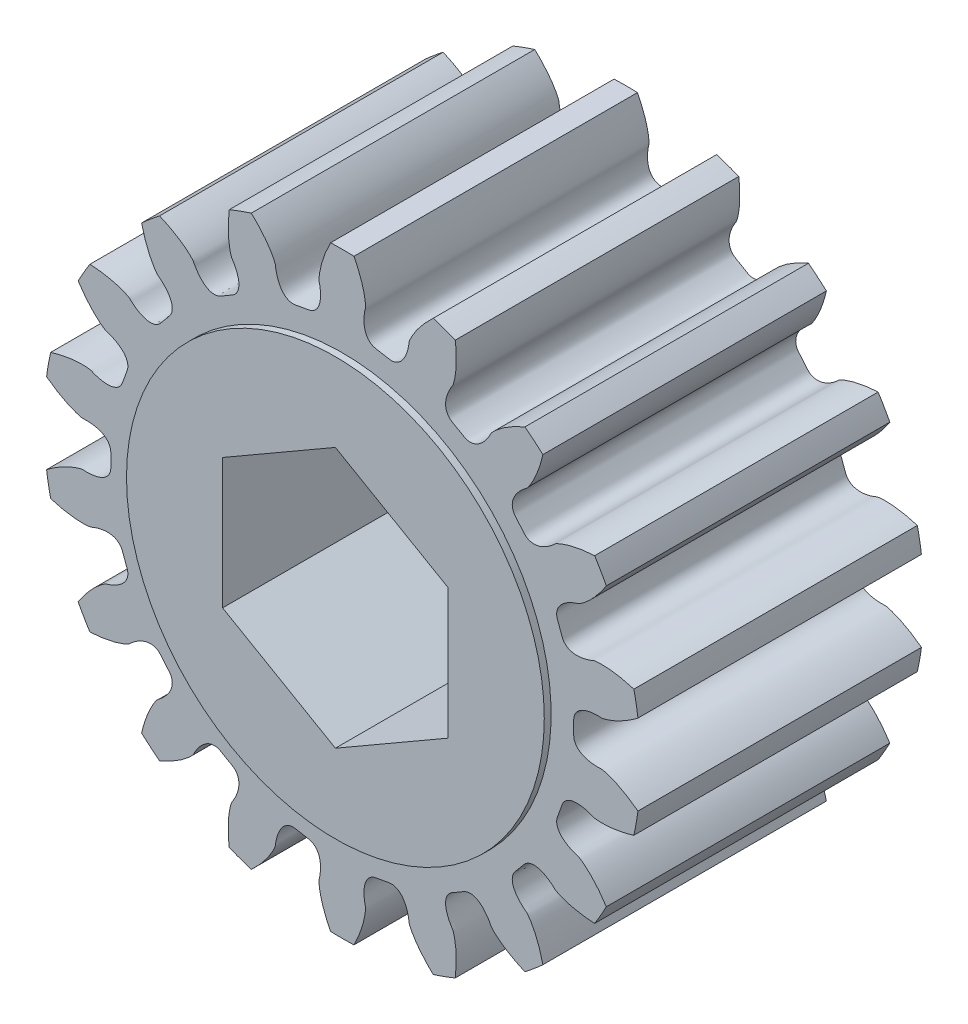
from build123d import *

# Parameters (mm, degrees)
BOSS_EXTRUDE1_DEPTH = 12.065
SKETCH2_R           = 8.89
BOSS_EXTRUDE2_DEPTH = 0.2921
SKETCH3_R           = 8.89
BOSS_EXTRUDE3_DEPTH = 0.2921
CUT_EXTRUDE1_DEPTH  = 13.6492


with BuildPart() as part:
    # Sketch1 → Boss-Extrude1 (new body)
    with BuildSketch(Plane.XY.offset(6.0325)):
        with BuildLine():
            ThreePointArc((12.410970883, -2.694030306), (12.507058369, -2.205331838), (12.583910389, -1.713241638))
            add(Edge.make_bspline(
                [(12.583910389, -1.713241638), (12.454495513, -1.615266365), (12.281691884, -1.494600081), (12.063530587, -1.360821083), (11.945634884, -1.293014345), (11.833605036, -1.232708673), (11.727763905, -1.179517154), (11.628417021, -1.133040061), (11.535852234, -1.09286743), (11.450339429, -1.058575143), (11.372129731, -1.029740178), (11.301456539, -1.005894736), (11.238530851, -0.986673766), (11.183554417, -0.971362731), (11.126066888, -0.957744243), (11.037383924, -0.935500863), (10.935383555, -0.952855993), (10.832757273, -0.948980949), (10.755684694, -0.945835715), (10.681454151, -0.939599556), (10.609986165, -0.931080188), (10.541241018, -0.920104184), (10.475144099, -0.906715101), (10.411601978, -0.890856967), (10.350496087, -0.872438809), (10.291684118, -0.851296022), (10.23500406, -0.827170041), (10.180287123, -0.799673241), (10.127386898, -0.768246797), (10.076238411, -0.732113156), (10.026966573, -0.690238537), (9.98006979, -0.641341891), (9.936675165, -0.584030203), (9.898843597, -0.517153755), (9.869552788, -0.440522263), (9.854050846, -0.362318712), (9.847049326, -0.214546824), (9.861767648, -5e-09), (9.847049326, 0.214546814), (9.854050846, 0.362318702), (9.869552789, 0.440522252), (9.898843597, 0.517153744), (9.936675165, 0.584030193), (9.980069791, 0.641341881), (10.026966574, 0.690238527), (10.076238412, 0.732113146), (10.127386899, 0.768246787), (10.180287124, 0.79967323), (10.235004061, 0.82717003), (10.291684119, 0.851296011), (10.350496088, 0.872438798), (10.411601979, 0.890856956), (10.4751441, 0.90671509), (10.541241019, 0.920104174), (10.609986166, 0.931080178), (10.681454152, 0.939599545), (10.755684695, 0.945835704), (10.832757274, 0.948980938), (10.935383556, 0.952855982), (11.037383925, 0.935500852), (11.126066889, 0.957744232), (11.183554418, 0.97136272), (11.238530852, 0.986673755), (11.30145654, 1.005894724), (11.372129732, 1.029740166), (11.45033943, 1.058575132), (11.535852235, 1.092867418), (11.628417022, 1.133040049), (11.727763907, 1.179517142), (11.833605037, 1.23270866), (11.945634885, 1.293014333), (12.063530588, 1.360821071), (12.281691885, 1.494600068), (12.454495515, 1.615266353), (12.58391039, 1.713241625)],
                knots=[0, 0, 0, 0, 0.068568258, 0.088954796, 0.108105787, 0.12602123, 0.142701125, 0.158145472, 0.172354272, 0.185327523, 0.197065227, 0.207567384, 0.216833992, 0.224865053, 0.231660567, 0.241835881, 0.263155637, 0.274398239, 0.285253325, 0.295735543, 0.30586243, 0.315655123, 0.325139277, 0.334346238, 0.343314557, 0.352091904, 0.360737466, 0.369324816, 0.377945084, 0.386709838, 0.395752205, 0.405223204, 0.415278018, 0.42604547, 0.437577809, 0.44979349, 0.459544035, 0.500000005, 0.540455975, 0.550206519, 0.5624222, 0.573954539, 0.584721991, 0.594776805, 0.604247805, 0.613290172, 0.622054925, 0.630675194, 0.639262544, 0.647908106, 0.656685453, 0.665653771, 0.674860733, 0.684344886, 0.69413758, 0.704264467, 0.714746685, 0.725601771, 0.736844372, 0.758164128, 0.768339443, 0.775134956, 0.783166017, 0.792432626, 0.802934782, 0.814672486, 0.827645738, 0.841854537, 0.857298885, 0.87397878, 0.891894222, 0.911045213, 0.931431751, 1.000000005, 1.000000005, 1.000000005, 1.000000005], degree=3))
            ThreePointArc((12.58391039, 1.713241625), (12.507058371, 2.205331832), (12.410970883, 2.694030306))
            add(Edge.make_bspline(
                [(12.410970883, 2.694030306), (12.255851163, 2.741834452), (12.052198568, 2.796121347), (11.801438895, 2.847216926), (11.667461903, 2.870611712), (11.541562526, 2.888964043), (11.423911826, 2.902747921), (11.31466019, 2.912443467), (11.213937893, 2.91853437), (11.121853489, 2.921511477), (11.038498274, 2.921858189), (10.963931576, 2.92009392), (10.898226812, 2.91663387), (10.84132918, 2.912218489), (10.782650776, 2.905353789), (10.691708366, 2.895924368), (10.601795176, 2.8447297), (10.504032672, 2.813270795), (10.430532405, 2.789865973), (10.35864562, 2.770337704), (10.288573885, 2.7538998), (10.220220564, 2.740701645), (10.153530441, 2.730676791), (10.088396577, 2.723845877), (10.024676441, 2.720253838), (9.962180009, 2.720006681), (9.900666605, 2.723291966), (9.839845043, 2.730416211), (9.779386616, 2.741854465), (9.718964327, 2.758315169), (9.658341981, 2.780812478), (9.597549782, 2.810720651), (9.537170421, 2.849734185), (9.478747284, 2.899638332), (9.425013413, 2.961630333), (9.383699162, 3.029815656), (9.326578923, 3.166281147), (9.267030288, 3.372923173), (9.179820255, 3.569497273), (9.13585857, 3.710752086), (9.123678441, 3.789541362), (9.124993284, 3.871569456), (9.137670236, 3.94735192), (9.158846094, 4.016049126), (9.186191017, 4.078036588), (9.218169437, 4.13423782), (9.253874859, 4.185686149), (9.292836333, 4.233310288), (9.334848976, 4.277863123), (9.379859237, 4.319919851), (9.427893151, 4.359902449), (9.479014525, 4.398109302), (9.533300786, 4.434743759), (9.590832237, 4.46993186), (9.651677529, 4.503758155), (9.715921673, 4.536207233), (9.783542674, 4.567455646), (9.854891475, 4.596771573), (9.950003292, 4.63551318), (10.05178809, 4.654090873), (10.127515133, 4.705324173), (10.176877942, 4.737783259), (10.223302209, 4.770973973), (10.275859055, 4.810557629), (10.33411451, 4.85713667), (10.397745447, 4.910981967), (10.466372546, 4.972453278), (10.539615145, 5.041862224), (10.617074577, 5.119515041), (10.698340136, 5.205698517), (10.782988003, 5.300683777), (10.870582454, 5.404723974), (11.029831903, 5.605050669), (11.150943898, 5.777542208), (11.239044585, 5.913871343)],
                knots=[0, 0, 0, 0, 0.068568258, 0.088954796, 0.108105787, 0.12602123, 0.142701125, 0.158145472, 0.172354272, 0.185327523, 0.197065227, 0.207567384, 0.216833992, 0.224865053, 0.231660567, 0.241835881, 0.263155637, 0.274398239, 0.285253325, 0.295735543, 0.30586243, 0.315655123, 0.325139277, 0.334346238, 0.343314557, 0.352091904, 0.360737466, 0.369324816, 0.377945084, 0.386709838, 0.395752205, 0.405223204, 0.415278018, 0.42604547, 0.437577809, 0.44979349, 0.459544035, 0.500000005, 0.540455975, 0.550206519, 0.5624222, 0.573954539, 0.584721991, 0.594776805, 0.604247805, 0.613290172, 0.622054925, 0.630675194, 0.639262544, 0.647908106, 0.656685453, 0.665653771, 0.674860733, 0.684344886, 0.69413758, 0.704264467, 0.714746685, 0.725601771, 0.736844372, 0.758164128, 0.768339443, 0.775134956, 0.783166017, 0.792432626, 0.802934782, 0.814672486, 0.827645738, 0.841854537, 0.857298885, 0.87397878, 0.891894222, 0.911045213, 0.931431751, 1.000000005, 1.000000005, 1.000000005, 1.000000005], degree=3))
            ThreePointArc((11.239044585, 5.913871343), (10.998522549, 6.349999934), (10.741085127, 6.776362423))
            add(Edge.make_bspline(
                [(10.741085127, 6.776362423), (10.57897029, 6.768229557), (10.369032237, 6.749589262), (10.115919506, 6.711838541), (9.982020827, 6.687999619), (9.857437245, 6.662185046), (9.742167386, 6.634898745), (9.636188358, 6.606643318), (9.539457148, 6.57791784), (9.451907882, 6.549220684), (9.373461019, 6.521037324), (9.303994658, 6.493876141), (9.243435784, 6.468152405), (9.191479648, 6.444543168), (9.138687851, 6.418023263), (9.05645499, 6.378058371), (8.989473837, 6.299198996), (8.908366713, 6.23620055), (8.847303975, 6.189068639), (8.786431555, 6.146131341), (8.726207757, 6.106718819), (8.66649068, 6.070938398), (8.607251166, 6.03870875), (8.548381665, 6.010012697), (8.489732872, 5.984843715), (8.431089969, 5.963236424), (8.372162644, 5.945284759), (8.312572436, 5.931177161), (8.251847984, 5.921247604), (8.189439713, 5.916049966), (8.124778809, 5.916456458), (8.057423631, 5.92376879), (7.987342176, 5.939778563), (7.915374162, 5.966691232), (7.843678327, 6.006566591), (7.781534876, 6.05650953), (7.681185462, 6.165208873), (7.554552314, 6.339022027), (7.405369388, 6.49391367), (7.315746925, 6.611613994), (7.277353829, 6.681485846), (7.250534116, 6.759016743), (7.236527426, 6.834564738), (7.232930395, 6.906361566), (7.237425257, 6.97396324), (7.248253188, 7.037712387), (7.264208945, 7.098269976), (7.28453234, 7.156347637), (7.308773343, 7.212582777), (7.336684905, 7.26749759), (7.368147166, 7.321497509), (7.40311803, 7.374884747), (7.441600707, 7.42787687), (7.483627548, 7.480619784), (7.529234146, 7.533216419), (7.578505655, 7.58568137), (7.631361024, 7.638173018), (7.688380328, 7.690123705), (7.764505791, 7.759059064), (7.85379827, 7.811328837), (7.907435592, 7.885372565), (7.942719799, 7.932757203), (7.974992447, 7.979824307), (8.010841319, 8.034996277), (8.04965257, 8.098690797), (8.091029917, 8.171051887), (8.134493868, 8.252287874), (8.17958014, 8.342561393), (8.225809369, 8.442023858), (8.27269753, 8.550804293), (8.319753634, 8.669012516), (8.36648165, 8.796737388), (8.447611417, 9.039449425), (8.502423885, 9.242961193), (8.53858414, 9.401200885)],
                knots=[0, 0, 0, 0, 0.068568258, 0.088954796, 0.108105787, 0.12602123, 0.142701125, 0.158145472, 0.172354272, 0.185327523, 0.197065227, 0.207567384, 0.216833992, 0.224865053, 0.231660567, 0.241835881, 0.263155637, 0.274398239, 0.285253325, 0.295735543, 0.30586243, 0.315655123, 0.325139277, 0.334346238, 0.343314557, 0.352091904, 0.360737466, 0.369324816, 0.377945084, 0.386709838, 0.395752205, 0.405223204, 0.415278018, 0.42604547, 0.437577809, 0.44979349, 0.459544035, 0.500000005, 0.540455975, 0.550206519, 0.5624222, 0.573954539, 0.584721991, 0.594776805, 0.604247805, 0.613290172, 0.622054925, 0.630675194, 0.639262544, 0.647908106, 0.656685453, 0.665653771, 0.674860733, 0.684344886, 0.69413758, 0.704264467, 0.714746685, 0.725601771, 0.736844372, 0.758164128, 0.768339443, 0.775134956, 0.783166017, 0.792432626, 0.802934782, 0.814672486, 0.827645738, 0.841854537, 0.857298885, 0.87397878, 0.891894222, 0.911045213, 0.931431751, 1.000000005, 1.000000005, 1.000000005, 1.000000005], degree=3))
            ThreePointArc((8.53858414, 9.401200885), (8.163402594, 9.728764322), (7.775665989, 10.041365223))
            add(Edge.make_bspline(
                [(7.775665989, 10.041365223), (7.626109477, 9.978276289), (7.435207594, 9.888957098), (7.210270936, 9.766913371), (7.092600726, 9.698716067), (6.984359558, 9.631848209), (6.885373786, 9.56678286), (6.795450001, 9.503984481), (6.714377089, 9.443907339), (6.641922695, 9.386997221), (6.577846033, 9.333683118), (6.521858679, 9.28440106), (6.473749987, 9.2395163), (6.433002025, 9.199560829), (6.392464304, 9.156584413), (6.32885949, 9.090904403), (6.292889289, 8.993891927), (6.238220261, 8.906952482), (6.196960119, 8.841778287), (6.154444176, 8.780610831), (6.111332194, 8.722977423), (6.067454122, 8.668930382), (6.022810376, 8.618383312), (5.977305769, 8.571283288), (5.93080223, 8.527573113), (5.883086055, 8.487211847), (5.833852314, 8.450188467), (5.782680918, 8.41655061), (5.729014708, 8.386450893), (5.672147813, 8.360221825), (5.61124741, 8.338488471), (5.545453281, 8.322322988), (5.47412259, 8.313397984), (5.397290103, 8.31407311), (5.31627988, 8.327022271), (5.240802647, 8.352698971), (5.109327678, 8.42052142), (4.930883844, 8.54054127), (4.737721687, 8.635068239), (4.613248238, 8.715017677), (4.553272948, 8.767544528), (4.501553533, 8.831226859), (4.462552614, 8.897428182), (4.434616549, 8.963664873), (4.415719203, 9.028727002), (4.404090638, 9.092334975), (4.39837223, 9.154697685), (4.397606244, 9.216223845), (4.401151785, 9.277358502), (4.408598102, 9.338507863), (4.419693896, 9.400011916), (4.434296249, 9.462140249), (4.452333762, 9.525098407), (4.473786935, 9.58903456), (4.49865401, 9.654057605), (4.527010014, 9.720210381), (4.558724614, 9.787613996), (4.594537051, 9.855933424), (4.642494306, 9.946747914), (4.708524474, 10.02640526), (4.733602623, 10.114328649), (4.750552431, 10.170923554), (4.764780903, 10.22619006), (4.779597899, 10.290295789), (4.794283736, 10.363423289), (4.808416773, 10.445572357), (4.821475183, 10.536774762), (4.832967058, 10.637024535), (4.842390157, 10.746300007), (4.849245516, 10.864556874), (4.853034196, 10.991730405), (4.853259689, 11.127734447), (4.846484327, 11.383557171), (4.828386074, 11.593542647), (4.808244437, 11.754606853)],
                knots=[0, 0, 0, 0, 0.068568258, 0.088954796, 0.108105787, 0.12602123, 0.142701125, 0.158145472, 0.172354272, 0.185327523, 0.197065227, 0.207567384, 0.216833992, 0.224865053, 0.231660567, 0.241835881, 0.263155637, 0.274398239, 0.285253325, 0.295735543, 0.30586243, 0.315655123, 0.325139277, 0.334346238, 0.343314557, 0.352091904, 0.360737466, 0.369324816, 0.377945084, 0.386709838, 0.395752205, 0.405223204, 0.415278018, 0.42604547, 0.437577809, 0.44979349, 0.459544035, 0.500000005, 0.540455975, 0.550206519, 0.5624222, 0.573954539, 0.584721991, 0.594776805, 0.604247805, 0.613290172, 0.622054925, 0.630675194, 0.639262544, 0.647908106, 0.656685453, 0.665653771, 0.674860733, 0.684344886, 0.69413758, 0.704264467, 0.714746685, 0.725601771, 0.736844372, 0.758164128, 0.768339443, 0.775134956, 0.783166017, 0.792432626, 0.802934782, 0.814672486, 0.827645738, 0.841854537, 0.857298885, 0.87397878, 0.891894222, 0.911045213, 0.931431751, 1.000000005, 1.000000005, 1.000000005, 1.000000005], degree=3))
            ThreePointArc((4.808244437, 11.754606853), (4.343655813, 11.934096152), (3.872386782, 12.095231182))
            add(Edge.make_bspline(
                [(3.872386782, 12.095231182), (3.753427317, 11.984795637), (3.604587189, 11.835570763), (3.434957284, 11.643954305), (3.347708308, 11.53962422), (3.268865036, 11.439768327), (3.198102496, 11.344771771), (3.13508009, 11.255004851), (3.079444065, 11.170822235), (3.030823612, 11.092563355), (2.988845743, 11.020548977), (2.953090296, 10.955090188), (2.923234405, 10.896458169), (2.898609422, 10.844975684), (2.875215224, 10.790726345), (2.837910136, 10.707253197), (2.837289425, 10.603788756), (2.815652384, 10.503394492), (2.799171421, 10.428038982), (2.780140005, 10.356019066), (2.75933978, 10.287116212), (2.736593057, 10.221321422), (2.711929774, 10.158553653), (2.685278587, 10.098730616), (2.656529316, 10.04175134), (2.625495144, 9.987504263), (2.591893302, 9.935874735), (2.555312744, 9.886763841), (2.515177711, 9.840124434), (2.47071118, 9.796027549), (2.420916765, 9.754775711), (2.364619428, 9.717082209), (2.300643036, 9.684298916), (2.228213209, 9.658655068), (2.147659626, 9.643116171), (2.067952278, 9.641429642), (1.921209576, 9.66019481), (1.712478015, 9.711945192), (1.498634835, 9.734706138), (1.354323736, 9.767261608), (1.280000156, 9.796107945), (1.209619164, 9.83826068), (1.150328102, 9.887130474), (1.101422505, 9.939817908), (1.06141225, 9.994493037), (1.028729765, 10.050287777), (1.002026917, 10.106933744), (0.980263939, 10.16448744), (0.962686374, 10.223147873), (0.948769309, 10.283156266), (0.93816032, 10.344746156), (0.930632902, 10.408121991), (0.926049662, 10.4734525), (0.924341599, 10.540870249), (0.925469814, 10.610476965), (0.92949016, 10.682338565), (0.936238741, 10.756524276), (0.946524804, 10.832972114), (0.960529497, 10.934712167), (0.995333141, 11.032149235), (0.988827324, 11.123347427), (0.985398336, 11.182326417), (0.979866467, 11.239126369), (0.971864438, 11.30443376), (0.960653533, 11.378173985), (0.945837607, 11.460202641), (0.92691544, 11.550371108), (0.903426828, 11.648505532), (0.874907232, 11.754413776), (0.840902932, 11.867883553), (0.800967217, 11.988683386), (0.754662989, 12.116562504), (0.660799707, 12.35463992), (0.571973649, 12.545771754), (0.497959499, 12.690233755)],
                knots=[0, 0, 0, 0, 0.068568258, 0.088954796, 0.108105787, 0.12602123, 0.142701125, 0.158145472, 0.172354272, 0.185327523, 0.197065227, 0.207567384, 0.216833992, 0.224865053, 0.231660567, 0.241835881, 0.263155637, 0.274398239, 0.285253325, 0.295735543, 0.30586243, 0.315655123, 0.325139277, 0.334346238, 0.343314557, 0.352091904, 0.360737466, 0.369324816, 0.377945084, 0.386709838, 0.395752205, 0.405223204, 0.415278018, 0.42604547, 0.437577809, 0.44979349, 0.459544035, 0.500000005, 0.540455975, 0.550206519, 0.5624222, 0.573954539, 0.584721991, 0.594776805, 0.604247805, 0.613290172, 0.622054925, 0.630675194, 0.639262544, 0.647908106, 0.656685453, 0.665653771, 0.674860733, 0.684344886, 0.69413758, 0.704264467, 0.714746685, 0.725601771, 0.736844372, 0.758164128, 0.768339443, 0.775134956, 0.783166017, 0.792432626, 0.802934782, 0.814672486, 0.827645738, 0.841854537, 0.857298885, 0.87397878, 0.891894222, 0.911045213, 0.931431751, 1.000000005, 1.000000005, 1.000000005, 1.000000005], degree=3))
            ThreePointArc((0.497959499, 12.690233755), (4.2e-08, 12.699999857), (-0.497959416, 12.690233754))
            add(Edge.make_bspline(
                [(-0.497959416, 12.690233754), (-0.571973566, 12.545771754), (-0.660799623, 12.354639919), (-0.754662905, 12.116562503), (-0.800967133, 11.988683385), (-0.840902847, 11.867883552), (-0.874907148, 11.754413776), (-0.903426744, 11.648505531), (-0.926915355, 11.550371107), (-0.945837523, 11.46020264), (-0.960653449, 11.378173984), (-0.971864354, 11.304433759), (-0.979866382, 11.239126368), (-0.985398251, 11.182326416), (-0.988827239, 11.123347426), (-0.995333057, 11.032149233), (-0.960529412, 10.934712166), (-0.946524718, 10.832972113), (-0.936238656, 10.756524275), (-0.929490075, 10.682338564), (-0.925469729, 10.610476964), (-0.924341513, 10.540870248), (-0.926049577, 10.473452499), (-0.930632816, 10.40812199), (-0.938160235, 10.344746155), (-0.948769224, 10.283156265), (-0.962686288, 10.223147872), (-0.980263854, 10.164487439), (-1.002026831, 10.106933743), (-1.028729679, 10.050287776), (-1.061412164, 9.994493036), (-1.101422419, 9.939817907), (-1.150328016, 9.887130473), (-1.209619078, 9.838260679), (-1.28000007, 9.796107944), (-1.354323649, 9.767261607), (-1.498634749, 9.734706137), (-1.712477929, 9.71194519), (-1.92120949, 9.660194808), (-2.067952192, 9.64142964), (-2.147659539, 9.643116169), (-2.228213122, 9.658655066), (-2.30064295, 9.684298913), (-2.364619342, 9.717082207), (-2.420916679, 9.754775709), (-2.470711094, 9.796027546), (-2.515177625, 9.840124431), (-2.555312658, 9.886763838), (-2.591893216, 9.935874733), (-2.625495058, 9.987504261), (-2.65652923, 10.041751337), (-2.685278501, 10.098730613), (-2.711929688, 10.158553651), (-2.736592971, 10.221321419), (-2.759339694, 10.287116209), (-2.78013992, 10.356019063), (-2.799171336, 10.42803898), (-2.815652299, 10.503394489), (-2.837289339, 10.603788753), (-2.837910051, 10.707253194), (-2.875215139, 10.790726342), (-2.898609336, 10.844975681), (-2.92323432, 10.896458166), (-2.953090211, 10.955090185), (-2.988845658, 11.020548974), (-3.030823527, 11.092563352), (-3.07944398, 11.170822232), (-3.135080005, 11.255004848), (-3.198102412, 11.344771768), (-3.268864951, 11.439768323), (-3.347708224, 11.539624216), (-3.434957199, 11.643954302), (-3.604587105, 11.835570759), (-3.753427233, 11.984795633), (-3.872386698, 12.095231178)],
                knots=[0, 0, 0, 0, 0.068568258, 0.088954796, 0.108105787, 0.12602123, 0.142701125, 0.158145472, 0.172354272, 0.185327523, 0.197065227, 0.207567384, 0.216833992, 0.224865053, 0.231660567, 0.241835881, 0.263155637, 0.274398239, 0.285253325, 0.295735543, 0.30586243, 0.315655123, 0.325139277, 0.334346238, 0.343314557, 0.352091904, 0.360737466, 0.369324816, 0.377945084, 0.386709838, 0.395752205, 0.405223204, 0.415278018, 0.42604547, 0.437577809, 0.44979349, 0.459544035, 0.500000005, 0.540455975, 0.550206519, 0.5624222, 0.573954539, 0.584721991, 0.594776805, 0.604247805, 0.613290172, 0.622054925, 0.630675194, 0.639262544, 0.647908106, 0.656685453, 0.665653771, 0.674860733, 0.684344886, 0.69413758, 0.704264467, 0.714746685, 0.725601771, 0.736844372, 0.758164128, 0.768339443, 0.775134956, 0.783166017, 0.792432626, 0.802934782, 0.814672486, 0.827645738, 0.841854537, 0.857298885, 0.87397878, 0.891894222, 0.911045213, 0.931431751, 1.000000005, 1.000000005, 1.000000005, 1.000000005], degree=3))
            ThreePointArc((-3.872386698, 12.095231178), (-4.343655729, 11.934096147), (-4.808244353, 11.754606848))
            add(Edge.make_bspline(
                [(-4.808244353, 11.754606848), (-4.82838599, 11.593542642), (-4.846484243, 11.383557166), (-4.853259604, 11.127734442), (-4.853034111, 10.9917304), (-4.849245431, 10.864556869), (-4.842390072, 10.746300002), (-4.832966973, 10.63702453), (-4.821475098, 10.536774757), (-4.808416687, 10.445572352), (-4.794283651, 10.363423284), (-4.779597813, 10.290295784), (-4.764780817, 10.226190055), (-4.750552345, 10.170923549), (-4.733602538, 10.114328644), (-4.708524388, 10.026405255), (-4.64249422, 9.946747909), (-4.594536965, 9.855933419), (-4.558724527, 9.787613991), (-4.527009928, 9.720210376), (-4.498653924, 9.6540576), (-4.473786849, 9.589034555), (-4.452333676, 9.525098402), (-4.434296162, 9.462140244), (-4.419693809, 9.400011911), (-4.408598015, 9.338507859), (-4.401151699, 9.277358498), (-4.397606157, 9.21622384), (-4.398372143, 9.15469768), (-4.404090551, 9.092334971), (-4.415719116, 9.028726997), (-4.434616462, 8.963664869), (-4.462552527, 8.897428177), (-4.501553446, 8.831226854), (-4.553272861, 8.767544524), (-4.613248151, 8.715017672), (-4.7377216, 8.635068234), (-4.930883756, 8.540541265), (-5.109327591, 8.420521415), (-5.240802559, 8.352698965), (-5.316279792, 8.327022266), (-5.397290015, 8.314073104), (-5.474122503, 8.313397978), (-5.545453193, 8.322322982), (-5.611247322, 8.338488465), (-5.672147725, 8.360221819), (-5.72901462, 8.386450887), (-5.78268083, 8.416550604), (-5.833852226, 8.450188461), (-5.883085968, 8.487211841), (-5.930802143, 8.527573107), (-5.977305681, 8.571283282), (-6.022810289, 8.618383306), (-6.067454035, 8.668930375), (-6.111332106, 8.722977417), (-6.154444089, 8.780610824), (-6.196960032, 8.84177828), (-6.238220174, 8.906952475), (-6.292889201, 8.993891921), (-6.328859403, 9.090904397), (-6.392464217, 9.156584406), (-6.433001938, 9.199560823), (-6.4737499, 9.239516293), (-6.521858592, 9.284401053), (-6.577845946, 9.333683111), (-6.641922608, 9.386997214), (-6.714377002, 9.443907332), (-6.795449914, 9.503984474), (-6.8853737, 9.566782853), (-6.984359472, 9.631848201), (-7.09260064, 9.69871606), (-7.210270849, 9.766913364), (-7.435207508, 9.88895709), (-7.626109391, 9.978276281), (-7.775665903, 10.041365215)],
                knots=[0, 0, 0, 0, 0.068568258, 0.088954796, 0.108105787, 0.12602123, 0.142701125, 0.158145472, 0.172354272, 0.185327523, 0.197065227, 0.207567384, 0.216833992, 0.224865053, 0.231660567, 0.241835881, 0.263155637, 0.274398239, 0.285253325, 0.295735543, 0.30586243, 0.315655123, 0.325139277, 0.334346238, 0.343314557, 0.352091904, 0.360737466, 0.369324816, 0.377945084, 0.386709838, 0.395752205, 0.405223204, 0.415278018, 0.42604547, 0.437577809, 0.44979349, 0.459544035, 0.500000005, 0.540455975, 0.550206519, 0.5624222, 0.573954539, 0.584721991, 0.594776805, 0.604247805, 0.613290172, 0.622054925, 0.630675194, 0.639262544, 0.647908106, 0.656685453, 0.665653771, 0.674860733, 0.684344886, 0.69413758, 0.704264467, 0.714746685, 0.725601771, 0.736844372, 0.758164128, 0.768339443, 0.775134956, 0.783166017, 0.792432626, 0.802934782, 0.814672486, 0.827645738, 0.841854537, 0.857298885, 0.87397878, 0.891894222, 0.911045213, 0.931431751, 1.000000005, 1.000000005, 1.000000005, 1.000000005], degree=3))
            ThreePointArc((-7.775665903, 10.041365215), (-8.163402508, 9.728764314), (-8.538584053, 9.401200876))
            add(Edge.make_bspline(
                [(-8.538584053, 9.401200876), (-8.502423798, 9.242961184), (-8.44761133, 9.039449416), (-8.366481563, 8.79673738), (-8.319753546, 8.669012508), (-8.272697442, 8.550804284), (-8.225809282, 8.44202385), (-8.179580052, 8.342561384), (-8.13449378, 8.252287866), (-8.091029829, 8.171051878), (-8.049652482, 8.098690788), (-8.010841231, 8.034996268), (-7.974992359, 7.979824299), (-7.942719711, 7.932757195), (-7.907435504, 7.885372557), (-7.853798181, 7.811328829), (-7.764505703, 7.759059056), (-7.68838024, 7.690123697), (-7.631360936, 7.63817301), (-7.578505567, 7.585681362), (-7.529234057, 7.533216411), (-7.483627459, 7.480619776), (-7.441600618, 7.427876863), (-7.403117941, 7.374884739), (-7.368147077, 7.321497502), (-7.336684816, 7.267497582), (-7.308773254, 7.21258277), (-7.284532251, 7.15634763), (-7.264208856, 7.098269968), (-7.248253099, 7.03771238), (-7.237425168, 6.973963233), (-7.232930305, 6.906361558), (-7.236527337, 6.834564731), (-7.250534027, 6.759016736), (-7.277353739, 6.681485838), (-7.315746836, 6.611613986), (-7.405369299, 6.493913663), (-7.554552225, 6.339022019), (-7.681185372, 6.165208865), (-7.781534786, 6.056509522), (-7.843678237, 6.006566583), (-7.915374072, 5.966691223), (-7.987342086, 5.939778555), (-8.057423541, 5.923768782), (-8.124778719, 5.916456449), (-8.189439623, 5.916049957), (-8.251847894, 5.921247596), (-8.312572346, 5.931177152), (-8.372162554, 5.94528475), (-8.431089879, 5.963236416), (-8.489732782, 5.984843706), (-8.548381574, 6.010012688), (-8.607251076, 6.038708741), (-8.66649059, 6.070938389), (-8.726207667, 6.10671881), (-8.786431465, 6.146131332), (-8.847303885, 6.18906863), (-8.908366623, 6.236200541), (-8.989473747, 6.299198987), (-9.056454901, 6.378058361), (-9.138687761, 6.418023254), (-9.191479559, 6.444543158), (-9.243435694, 6.468152395), (-9.303994569, 6.493876131), (-9.373460929, 6.521037315), (-9.451907792, 6.549220675), (-9.539457058, 6.57791783), (-9.636188269, 6.606643308), (-9.742167297, 6.634898735), (-9.857437156, 6.662185035), (-9.982020738, 6.687999609), (-10.115919417, 6.71183853), (-10.369032148, 6.749589251), (-10.578970201, 6.768229546), (-10.741085038, 6.776362412)],
                knots=[0, 0, 0, 0, 0.068568258, 0.088954796, 0.108105787, 0.12602123, 0.142701125, 0.158145472, 0.172354272, 0.185327523, 0.197065227, 0.207567384, 0.216833992, 0.224865053, 0.231660567, 0.241835881, 0.263155637, 0.274398239, 0.285253325, 0.295735543, 0.30586243, 0.315655123, 0.325139277, 0.334346238, 0.343314557, 0.352091904, 0.360737466, 0.369324816, 0.377945084, 0.386709838, 0.395752205, 0.405223204, 0.415278018, 0.42604547, 0.437577809, 0.44979349, 0.459544035, 0.500000005, 0.540455975, 0.550206519, 0.5624222, 0.573954539, 0.584721991, 0.594776805, 0.604247805, 0.613290172, 0.622054925, 0.630675194, 0.639262544, 0.647908106, 0.656685453, 0.665653771, 0.674860733, 0.684344886, 0.69413758, 0.704264467, 0.714746685, 0.725601771, 0.736844372, 0.758164128, 0.768339443, 0.775134956, 0.783166017, 0.792432626, 0.802934782, 0.814672486, 0.827645738, 0.841854537, 0.857298885, 0.87397878, 0.891894222, 0.911045213, 0.931431751, 1.000000005, 1.000000005, 1.000000005, 1.000000005], degree=3))
            ThreePointArc((-10.741085038, 6.776362412), (-10.998522459, 6.349999923), (-11.239044495, 5.913871331))
            add(Edge.make_bspline(
                [(-11.239044495, 5.913871331), (-11.150943808, 5.777542197), (-11.029831812, 5.605050658), (-10.870582363, 5.404723963), (-10.782987912, 5.300683766), (-10.698340045, 5.205698506), (-10.617074486, 5.11951503), (-10.539615054, 5.041862213), (-10.466372455, 4.972453267), (-10.397745356, 4.910981956), (-10.334114419, 4.85713666), (-10.275858964, 4.810557619), (-10.223302118, 4.770973963), (-10.176877851, 4.737783248), (-10.127515041, 4.705324163), (-10.051787999, 4.654090863), (-9.950003201, 4.635513169), (-9.854891383, 4.596771563), (-9.783542583, 4.567455636), (-9.715921582, 4.536207223), (-9.651677437, 4.503758145), (-9.590832145, 4.46993185), (-9.533300694, 4.434743749), (-9.479014433, 4.398109293), (-9.427893059, 4.35990244), (-9.379859145, 4.319919841), (-9.334848884, 4.277863113), (-9.292836241, 4.233310278), (-9.253874767, 4.185686139), (-9.218169345, 4.13423781), (-9.186190925, 4.078036578), (-9.158846002, 4.016049116), (-9.137670144, 3.94735191), (-9.124993192, 3.871569447), (-9.123678349, 3.789541353), (-9.135858477, 3.710752077), (-9.179820163, 3.569497263), (-9.267030195, 3.372923163), (-9.32657883, 3.166281138), (-9.383699069, 3.029815646), (-9.42501332, 2.961630323), (-9.47874719, 2.899638322), (-9.537170328, 2.849734175), (-9.597549689, 2.810720641), (-9.658341887, 2.780812468), (-9.718964234, 2.758315159), (-9.779386522, 2.741854455), (-9.83984495, 2.730416201), (-9.900666511, 2.723291955), (-9.962179915, 2.720006671), (-10.024676347, 2.720253828), (-10.088396483, 2.723845866), (-10.153530347, 2.73067678), (-10.220220471, 2.740701635), (-10.288573792, 2.75389979), (-10.358645527, 2.770337694), (-10.430532312, 2.789865962), (-10.504032579, 2.813270784), (-10.601795082, 2.844729689), (-10.691708273, 2.895924358), (-10.782650683, 2.905353778), (-10.841329087, 2.912218478), (-10.898226719, 2.916633859), (-10.963931482, 2.920093908), (-11.03849818, 2.921858178), (-11.121853396, 2.921511465), (-11.2139378, 2.918534358), (-11.314660097, 2.912443455), (-11.423911733, 2.90274791), (-11.541562433, 2.888964031), (-11.667461809, 2.8706117), (-11.801438801, 2.847216914), (-12.052198474, 2.796121335), (-12.25585107, 2.74183444), (-12.41097079, 2.694030294)],
                knots=[0, 0, 0, 0, 0.068568258, 0.088954796, 0.108105787, 0.12602123, 0.142701125, 0.158145472, 0.172354272, 0.185327523, 0.197065227, 0.207567384, 0.216833992, 0.224865053, 0.231660567, 0.241835881, 0.263155637, 0.274398239, 0.285253325, 0.295735543, 0.30586243, 0.315655123, 0.325139277, 0.334346238, 0.343314557, 0.352091904, 0.360737466, 0.369324816, 0.377945084, 0.386709838, 0.395752205, 0.405223204, 0.415278018, 0.42604547, 0.437577809, 0.44979349, 0.459544035, 0.500000005, 0.540455975, 0.550206519, 0.5624222, 0.573954539, 0.584721991, 0.594776805, 0.604247805, 0.613290172, 0.622054925, 0.630675194, 0.639262544, 0.647908106, 0.656685453, 0.665653771, 0.674860733, 0.684344886, 0.69413758, 0.704264467, 0.714746685, 0.725601771, 0.736844372, 0.758164128, 0.768339443, 0.775134956, 0.783166017, 0.792432626, 0.802934782, 0.814672486, 0.827645738, 0.841854537, 0.857298885, 0.87397878, 0.891894222, 0.911045213, 0.931431751, 1.000000005, 1.000000005, 1.000000005, 1.000000005], degree=3))
            ThreePointArc((-12.41097079, 2.694030294), (-12.507058275, 2.205331828), (-12.583910293, 1.713241631))
            add(Edge.make_bspline(
                [(-12.583910293, 1.713241631), (-12.454495418, 1.615266359), (-12.281691788, 1.494600075), (-12.063530491, 1.360821077), (-11.945634789, 1.293014339), (-11.83360494, 1.232708667), (-11.72776381, 1.179517148), (-11.628416925, 1.133040055), (-11.535852138, 1.092867424), (-11.450339333, 1.058575137), (-11.372129635, 1.029740172), (-11.301456443, 1.00589473), (-11.238530755, 0.986673761), (-11.183554321, 0.971362725), (-11.126066792, 0.957744237), (-11.037383829, 0.935500858), (-10.93538346, 0.952855987), (-10.832757177, 0.948980943), (-10.755684598, 0.94583571), (-10.681454055, 0.939599551), (-10.609986069, 0.931080183), (-10.541240923, 0.920104179), (-10.475144003, 0.906715096), (-10.411601882, 0.890856962), (-10.350495991, 0.872438803), (-10.291684022, 0.851296017), (-10.235003964, 0.827170036), (-10.180287027, 0.799673236), (-10.127386802, 0.768246792), (-10.076238316, 0.732113151), (-10.026966477, 0.690238532), (-9.980069694, 0.641341886), (-9.936675069, 0.584030198), (-9.898843501, 0.51715375), (-9.869552692, 0.440522258), (-9.85405075, 0.362318707), (-9.84704923, 0.214546819), (-9.861767552, 0), (-9.84704923, -0.214546819), (-9.85405075, -0.362318707), (-9.869552692, -0.440522258), (-9.898843501, -0.51715375), (-9.936675069, -0.584030198), (-9.980069694, -0.641341886), (-10.026966477, -0.690238532), (-10.076238316, -0.732113151), (-10.127386802, -0.768246792), (-10.180287027, -0.799673236), (-10.235003964, -0.827170036), (-10.291684022, -0.851296017), (-10.350495991, -0.872438803), (-10.411601882, -0.890856962), (-10.475144003, -0.906715096), (-10.541240923, -0.920104179), (-10.609986069, -0.931080183), (-10.681454055, -0.939599551), (-10.755684598, -0.94583571), (-10.832757177, -0.948980943), (-10.93538346, -0.952855987), (-11.037383829, -0.935500858), (-11.126066792, -0.957744237), (-11.183554321, -0.971362725), (-11.238530755, -0.986673761), (-11.301456443, -1.00589473), (-11.372129635, -1.029740172), (-11.450339333, -1.058575137), (-11.535852138, -1.092867424), (-11.628416925, -1.133040055), (-11.72776381, -1.179517148), (-11.83360494, -1.232708667), (-11.945634789, -1.293014339), (-12.063530491, -1.360821077), (-12.281691788, -1.494600075), (-12.454495418, -1.615266359), (-12.583910293, -1.713241631)],
                knots=[0, 0, 0, 0, 0.068568258, 0.088954796, 0.108105787, 0.12602123, 0.142701125, 0.158145472, 0.172354272, 0.185327523, 0.197065227, 0.207567384, 0.216833992, 0.224865053, 0.231660567, 0.241835881, 0.263155637, 0.274398239, 0.285253325, 0.295735543, 0.30586243, 0.315655123, 0.325139277, 0.334346238, 0.343314557, 0.352091904, 0.360737466, 0.369324816, 0.377945084, 0.386709838, 0.395752205, 0.405223204, 0.415278018, 0.42604547, 0.437577809, 0.44979349, 0.459544035, 0.500000005, 0.540455975, 0.550206519, 0.5624222, 0.573954539, 0.584721991, 0.594776805, 0.604247805, 0.613290172, 0.622054925, 0.630675194, 0.639262544, 0.647908106, 0.656685453, 0.665653771, 0.674860733, 0.684344886, 0.69413758, 0.704264467, 0.714746685, 0.725601771, 0.736844372, 0.758164128, 0.768339443, 0.775134956, 0.783166017, 0.792432626, 0.802934782, 0.814672486, 0.827645738, 0.841854537, 0.857298885, 0.87397878, 0.891894222, 0.911045213, 0.931431751, 1.000000005, 1.000000005, 1.000000005, 1.000000005], degree=3))
            ThreePointArc((-12.583910293, -1.713241631), (-12.507058275, -2.205331828), (-12.41097079, -2.694030294))
            add(Edge.make_bspline(
                [(-12.41097079, -2.694030294), (-12.25585107, -2.74183444), (-12.052198474, -2.796121335), (-11.801438801, -2.847216914), (-11.667461809, -2.8706117), (-11.541562433, -2.888964031), (-11.423911733, -2.90274791), (-11.314660097, -2.912443455), (-11.2139378, -2.918534358), (-11.121853396, -2.921511465), (-11.03849818, -2.921858178), (-10.963931482, -2.920093908), (-10.898226719, -2.916633859), (-10.841329087, -2.912218478), (-10.782650683, -2.905353778), (-10.691708273, -2.895924358), (-10.601795082, -2.844729689), (-10.504032579, -2.813270784), (-10.430532312, -2.789865962), (-10.358645527, -2.770337694), (-10.288573792, -2.75389979), (-10.220220471, -2.740701635), (-10.153530347, -2.73067678), (-10.088396483, -2.723845866), (-10.024676347, -2.720253828), (-9.962179915, -2.720006671), (-9.900666511, -2.723291955), (-9.83984495, -2.730416201), (-9.779386522, -2.741854455), (-9.718964234, -2.758315159), (-9.658341887, -2.780812468), (-9.597549689, -2.810720641), (-9.537170328, -2.849734175), (-9.47874719, -2.899638322), (-9.42501332, -2.961630323), (-9.383699069, -3.029815646), (-9.32657883, -3.166281138), (-9.267030195, -3.372923163), (-9.179820163, -3.569497263), (-9.135858477, -3.710752077), (-9.123678349, -3.789541353), (-9.124993192, -3.871569447), (-9.137670144, -3.94735191), (-9.158846002, -4.016049116), (-9.186190925, -4.078036578), (-9.218169345, -4.13423781), (-9.253874767, -4.185686139), (-9.292836241, -4.233310278), (-9.334848884, -4.277863113), (-9.379859145, -4.319919841), (-9.427893059, -4.35990244), (-9.479014433, -4.398109293), (-9.533300694, -4.434743749), (-9.590832145, -4.46993185), (-9.651677437, -4.503758145), (-9.715921582, -4.536207223), (-9.783542583, -4.567455636), (-9.854891383, -4.596771563), (-9.950003201, -4.635513169), (-10.051787999, -4.654090863), (-10.127515041, -4.705324163), (-10.176877851, -4.737783248), (-10.223302118, -4.770973963), (-10.275858964, -4.810557619), (-10.334114419, -4.85713666), (-10.397745356, -4.910981956), (-10.466372455, -4.972453267), (-10.539615054, -5.041862213), (-10.617074486, -5.11951503), (-10.698340045, -5.205698506), (-10.782987912, -5.300683766), (-10.870582363, -5.404723963), (-11.029831812, -5.605050658), (-11.150943808, -5.777542197), (-11.239044495, -5.913871331)],
                knots=[0, 0, 0, 0, 0.068568258, 0.088954796, 0.108105787, 0.12602123, 0.142701125, 0.158145472, 0.172354272, 0.185327523, 0.197065227, 0.207567384, 0.216833992, 0.224865053, 0.231660567, 0.241835881, 0.263155637, 0.274398239, 0.285253325, 0.295735543, 0.30586243, 0.315655123, 0.325139277, 0.334346238, 0.343314557, 0.352091904, 0.360737466, 0.369324816, 0.377945084, 0.386709838, 0.395752205, 0.405223204, 0.415278018, 0.42604547, 0.437577809, 0.44979349, 0.459544035, 0.500000005, 0.540455975, 0.550206519, 0.5624222, 0.573954539, 0.584721991, 0.594776805, 0.604247805, 0.613290172, 0.622054925, 0.630675194, 0.639262544, 0.647908106, 0.656685453, 0.665653771, 0.674860733, 0.684344886, 0.69413758, 0.704264467, 0.714746685, 0.725601771, 0.736844372, 0.758164128, 0.768339443, 0.775134956, 0.783166017, 0.792432626, 0.802934782, 0.814672486, 0.827645738, 0.841854537, 0.857298885, 0.87397878, 0.891894222, 0.911045213, 0.931431751, 1.000000005, 1.000000005, 1.000000005, 1.000000005], degree=3))
            ThreePointArc((-11.239044495, -5.913871331), (-10.998522459, -6.349999923), (-10.741085038, -6.776362412))
            add(Edge.make_bspline(
                [(-10.741085038, -6.776362412), (-10.578970201, -6.768229546), (-10.369032148, -6.749589251), (-10.115919417, -6.71183853), (-9.982020738, -6.687999609), (-9.857437156, -6.662185035), (-9.742167297, -6.634898735), (-9.636188269, -6.606643308), (-9.539457058, -6.57791783), (-9.451907792, -6.549220675), (-9.373460929, -6.521037315), (-9.303994569, -6.493876131), (-9.243435694, -6.468152395), (-9.191479559, -6.444543158), (-9.138687761, -6.418023254), (-9.056454901, -6.378058361), (-8.989473747, -6.299198987), (-8.908366623, -6.236200541), (-8.847303885, -6.18906863), (-8.786431465, -6.146131332), (-8.726207667, -6.10671881), (-8.66649059, -6.070938389), (-8.607251076, -6.038708741), (-8.548381574, -6.010012688), (-8.489732782, -5.984843706), (-8.431089879, -5.963236416), (-8.372162554, -5.94528475), (-8.312572346, -5.931177152), (-8.251847894, -5.921247596), (-8.189439623, -5.916049957), (-8.124778719, -5.916456449), (-8.057423541, -5.923768782), (-7.987342086, -5.939778555), (-7.915374072, -5.966691223), (-7.843678237, -6.006566583), (-7.781534786, -6.056509522), (-7.681185372, -6.165208865), (-7.554552225, -6.339022019), (-7.405369299, -6.493913663), (-7.315746836, -6.611613986), (-7.277353739, -6.681485838), (-7.250534027, -6.759016736), (-7.236527337, -6.834564731), (-7.232930305, -6.906361558), (-7.237425168, -6.973963233), (-7.248253099, -7.03771238), (-7.264208856, -7.098269968), (-7.284532251, -7.15634763), (-7.308773254, -7.21258277), (-7.336684816, -7.267497582), (-7.368147077, -7.321497502), (-7.403117941, -7.374884739), (-7.441600618, -7.427876863), (-7.483627459, -7.480619776), (-7.529234057, -7.533216411), (-7.578505567, -7.585681362), (-7.631360936, -7.63817301), (-7.68838024, -7.690123697), (-7.764505703, -7.759059056), (-7.853798181, -7.811328829), (-7.907435504, -7.885372557), (-7.942719711, -7.932757195), (-7.974992359, -7.979824299), (-8.010841231, -8.034996268), (-8.049652482, -8.098690788), (-8.091029829, -8.171051878), (-8.13449378, -8.252287866), (-8.179580052, -8.342561384), (-8.225809282, -8.44202385), (-8.272697442, -8.550804284), (-8.319753546, -8.669012508), (-8.366481563, -8.79673738), (-8.44761133, -9.039449416), (-8.502423798, -9.242961184), (-8.538584053, -9.401200876)],
                knots=[0, 0, 0, 0, 0.068568258, 0.088954796, 0.108105787, 0.12602123, 0.142701125, 0.158145472, 0.172354272, 0.185327523, 0.197065227, 0.207567384, 0.216833992, 0.224865053, 0.231660567, 0.241835881, 0.263155637, 0.274398239, 0.285253325, 0.295735543, 0.30586243, 0.315655123, 0.325139277, 0.334346238, 0.343314557, 0.352091904, 0.360737466, 0.369324816, 0.377945084, 0.386709838, 0.395752205, 0.405223204, 0.415278018, 0.42604547, 0.437577809, 0.44979349, 0.459544035, 0.500000005, 0.540455975, 0.550206519, 0.5624222, 0.573954539, 0.584721991, 0.594776805, 0.604247805, 0.613290172, 0.622054925, 0.630675194, 0.639262544, 0.647908106, 0.656685453, 0.665653771, 0.674860733, 0.684344886, 0.69413758, 0.704264467, 0.714746685, 0.725601771, 0.736844372, 0.758164128, 0.768339443, 0.775134956, 0.783166017, 0.792432626, 0.802934782, 0.814672486, 0.827645738, 0.841854537, 0.857298885, 0.87397878, 0.891894222, 0.911045213, 0.931431751, 1.000000005, 1.000000005, 1.000000005, 1.000000005], degree=3))
            ThreePointArc((-8.538584053, -9.401200876), (-8.163402508, -9.728764314), (-7.775665903, -10.041365215))
            add(Edge.make_bspline(
                [(-7.775665903, -10.041365215), (-7.626109391, -9.978276281), (-7.435207508, -9.88895709), (-7.210270849, -9.766913364), (-7.09260064, -9.69871606), (-6.984359472, -9.631848201), (-6.8853737, -9.566782853), (-6.795449914, -9.503984474), (-6.714377002, -9.443907332), (-6.641922608, -9.386997214), (-6.577845946, -9.333683111), (-6.521858592, -9.284401053), (-6.4737499, -9.239516293), (-6.433001938, -9.199560823), (-6.392464217, -9.156584406), (-6.328859403, -9.090904397), (-6.292889201, -8.993891921), (-6.238220174, -8.906952475), (-6.196960032, -8.84177828), (-6.154444089, -8.780610824), (-6.111332106, -8.722977417), (-6.067454035, -8.668930375), (-6.022810289, -8.618383306), (-5.977305681, -8.571283282), (-5.930802143, -8.527573107), (-5.883085968, -8.487211841), (-5.833852226, -8.450188461), (-5.78268083, -8.416550604), (-5.72901462, -8.386450887), (-5.672147725, -8.360221819), (-5.611247322, -8.338488465), (-5.545453193, -8.322322982), (-5.474122503, -8.313397978), (-5.397290015, -8.314073104), (-5.316279792, -8.327022266), (-5.240802559, -8.352698965), (-5.109327591, -8.420521415), (-4.930883756, -8.540541265), (-4.7377216, -8.635068234), (-4.613248151, -8.715017672), (-4.553272861, -8.767544524), (-4.501553446, -8.831226854), (-4.462552527, -8.897428177), (-4.434616462, -8.963664869), (-4.415719116, -9.028726997), (-4.404090551, -9.092334971), (-4.398372143, -9.15469768), (-4.397606157, -9.21622384), (-4.401151699, -9.277358498), (-4.408598015, -9.338507859), (-4.419693809, -9.400011911), (-4.434296162, -9.462140244), (-4.452333676, -9.525098402), (-4.473786849, -9.589034555), (-4.498653924, -9.6540576), (-4.527009928, -9.720210376), (-4.558724527, -9.787613991), (-4.594536965, -9.855933419), (-4.64249422, -9.946747909), (-4.708524388, -10.026405255), (-4.733602538, -10.114328644), (-4.750552345, -10.170923549), (-4.764780817, -10.226190055), (-4.779597813, -10.290295784), (-4.794283651, -10.363423284), (-4.808416687, -10.445572352), (-4.821475098, -10.536774757), (-4.832966973, -10.63702453), (-4.842390072, -10.746300002), (-4.849245431, -10.864556869), (-4.853034111, -10.9917304), (-4.853259604, -11.127734442), (-4.846484243, -11.383557166), (-4.82838599, -11.593542642), (-4.808244353, -11.754606848)],
                knots=[0, 0, 0, 0, 0.068568258, 0.088954796, 0.108105787, 0.12602123, 0.142701125, 0.158145472, 0.172354272, 0.185327523, 0.197065227, 0.207567384, 0.216833992, 0.224865053, 0.231660567, 0.241835881, 0.263155637, 0.274398239, 0.285253325, 0.295735543, 0.30586243, 0.315655123, 0.325139277, 0.334346238, 0.343314557, 0.352091904, 0.360737466, 0.369324816, 0.377945084, 0.386709838, 0.395752205, 0.405223204, 0.415278018, 0.42604547, 0.437577809, 0.44979349, 0.459544035, 0.500000005, 0.540455975, 0.550206519, 0.5624222, 0.573954539, 0.584721991, 0.594776805, 0.604247805, 0.613290172, 0.622054925, 0.630675194, 0.639262544, 0.647908106, 0.656685453, 0.665653771, 0.674860733, 0.684344886, 0.69413758, 0.704264467, 0.714746685, 0.725601771, 0.736844372, 0.758164128, 0.768339443, 0.775134956, 0.783166017, 0.792432626, 0.802934782, 0.814672486, 0.827645738, 0.841854537, 0.857298885, 0.87397878, 0.891894222, 0.911045213, 0.931431751, 1.000000005, 1.000000005, 1.000000005, 1.000000005], degree=3))
            ThreePointArc((-4.808244353, -11.754606848), (-4.343655729, -11.934096147), (-3.872386698, -12.095231178))
            add(Edge.make_bspline(
                [(-3.872386698, -12.095231178), (-3.753427233, -11.984795633), (-3.604587105, -11.835570759), (-3.434957199, -11.643954302), (-3.347708224, -11.539624216), (-3.268864951, -11.439768323), (-3.198102412, -11.344771768), (-3.135080005, -11.255004848), (-3.07944398, -11.170822232), (-3.030823527, -11.092563352), (-2.988845658, -11.020548974), (-2.953090211, -10.955090185), (-2.92323432, -10.896458166), (-2.898609336, -10.844975681), (-2.875215139, -10.790726342), (-2.837910051, -10.707253194), (-2.837289339, -10.603788753), (-2.815652299, -10.503394489), (-2.799171336, -10.42803898), (-2.78013992, -10.356019063), (-2.759339694, -10.287116209), (-2.736592971, -10.221321419), (-2.711929688, -10.158553651), (-2.685278501, -10.098730613), (-2.65652923, -10.041751337), (-2.625495058, -9.987504261), (-2.591893216, -9.935874733), (-2.555312658, -9.886763838), (-2.515177625, -9.840124431), (-2.470711094, -9.796027546), (-2.420916679, -9.754775709), (-2.364619342, -9.717082207), (-2.30064295, -9.684298913), (-2.228213122, -9.658655066), (-2.147659539, -9.643116169), (-2.067952192, -9.64142964), (-1.92120949, -9.660194808), (-1.712477929, -9.71194519), (-1.498634749, -9.734706137), (-1.354323649, -9.767261607), (-1.28000007, -9.796107944), (-1.209619078, -9.838260679), (-1.150328016, -9.887130473), (-1.101422419, -9.939817907), (-1.061412164, -9.994493036), (-1.028729679, -10.050287776), (-1.002026831, -10.106933743), (-0.980263854, -10.164487439), (-0.962686288, -10.223147872), (-0.948769224, -10.283156265), (-0.938160235, -10.344746155), (-0.930632816, -10.40812199), (-0.926049577, -10.473452499), (-0.924341513, -10.540870248), (-0.925469729, -10.610476964), (-0.929490075, -10.682338564), (-0.936238656, -10.756524275), (-0.946524718, -10.832972113), (-0.960529412, -10.934712166), (-0.995333057, -11.032149233), (-0.988827239, -11.123347426), (-0.985398251, -11.182326416), (-0.979866382, -11.239126368), (-0.971864354, -11.304433759), (-0.960653449, -11.378173984), (-0.945837523, -11.46020264), (-0.926915355, -11.550371107), (-0.903426744, -11.648505531), (-0.874907148, -11.754413776), (-0.840902847, -11.867883552), (-0.800967133, -11.988683385), (-0.754662905, -12.116562503), (-0.660799623, -12.354639919), (-0.571973566, -12.545771754), (-0.497959416, -12.690233754)],
                knots=[0, 0, 0, 0, 0.068568258, 0.088954796, 0.108105787, 0.12602123, 0.142701125, 0.158145472, 0.172354272, 0.185327523, 0.197065227, 0.207567384, 0.216833992, 0.224865053, 0.231660567, 0.241835881, 0.263155637, 0.274398239, 0.285253325, 0.295735543, 0.30586243, 0.315655123, 0.325139277, 0.334346238, 0.343314557, 0.352091904, 0.360737466, 0.369324816, 0.377945084, 0.386709838, 0.395752205, 0.405223204, 0.415278018, 0.42604547, 0.437577809, 0.44979349, 0.459544035, 0.500000005, 0.540455975, 0.550206519, 0.5624222, 0.573954539, 0.584721991, 0.594776805, 0.604247805, 0.613290172, 0.622054925, 0.630675194, 0.639262544, 0.647908106, 0.656685453, 0.665653771, 0.674860733, 0.684344886, 0.69413758, 0.704264467, 0.714746685, 0.725601771, 0.736844372, 0.758164128, 0.768339443, 0.775134956, 0.783166017, 0.792432626, 0.802934782, 0.814672486, 0.827645738, 0.841854537, 0.857298885, 0.87397878, 0.891894222, 0.911045213, 0.931431751, 1.000000005, 1.000000005, 1.000000005, 1.000000005], degree=3))
            ThreePointArc((-0.497959416, -12.690233754), (4.2e-08, -12.699999857), (0.497959499, -12.690233755))
            add(Edge.make_bspline(
                [(0.497959499, -12.690233755), (0.571973649, -12.545771754), (0.660799707, -12.35463992), (0.754662989, -12.116562504), (0.800967217, -11.988683386), (0.840902932, -11.867883553), (0.874907232, -11.754413776), (0.903426828, -11.648505532), (0.92691544, -11.550371108), (0.945837607, -11.460202641), (0.960653533, -11.378173985), (0.971864438, -11.30443376), (0.979866467, -11.239126369), (0.985398336, -11.182326417), (0.988827324, -11.123347427), (0.995333141, -11.032149235), (0.960529497, -10.934712167), (0.946524804, -10.832972114), (0.936238741, -10.756524276), (0.92949016, -10.682338565), (0.925469814, -10.610476965), (0.924341599, -10.540870249), (0.926049662, -10.4734525), (0.930632902, -10.408121991), (0.93816032, -10.344746156), (0.948769309, -10.283156266), (0.962686374, -10.223147873), (0.980263939, -10.16448744), (1.002026917, -10.106933744), (1.028729765, -10.050287777), (1.06141225, -9.994493037), (1.101422505, -9.939817908), (1.150328102, -9.887130474), (1.209619164, -9.83826068), (1.280000156, -9.796107945), (1.354323736, -9.767261608), (1.498634835, -9.734706138), (1.712478015, -9.711945192), (1.921209576, -9.66019481), (2.067952278, -9.641429642), (2.147659626, -9.643116171), (2.228213209, -9.658655068), (2.300643036, -9.684298916), (2.364619428, -9.717082209), (2.420916765, -9.754775711), (2.47071118, -9.796027549), (2.515177711, -9.840124434), (2.555312744, -9.886763841), (2.591893302, -9.935874735), (2.625495144, -9.987504263), (2.656529316, -10.04175134), (2.685278587, -10.098730616), (2.711929774, -10.158553653), (2.736593057, -10.221321422), (2.75933978, -10.287116212), (2.780140005, -10.356019066), (2.799171421, -10.428038982), (2.815652384, -10.503394492), (2.837289425, -10.603788756), (2.837910136, -10.707253197), (2.875215224, -10.790726345), (2.898609422, -10.844975684), (2.923234405, -10.896458169), (2.953090296, -10.955090188), (2.988845743, -11.020548977), (3.030823612, -11.092563355), (3.079444065, -11.170822235), (3.13508009, -11.255004851), (3.198102496, -11.344771771), (3.268865036, -11.439768327), (3.347708308, -11.53962422), (3.434957284, -11.643954305), (3.604587189, -11.835570763), (3.753427317, -11.984795637), (3.872386782, -12.095231182)],
                knots=[0, 0, 0, 0, 0.068568258, 0.088954796, 0.108105787, 0.12602123, 0.142701125, 0.158145472, 0.172354272, 0.185327523, 0.197065227, 0.207567384, 0.216833992, 0.224865053, 0.231660567, 0.241835881, 0.263155637, 0.274398239, 0.285253325, 0.295735543, 0.30586243, 0.315655123, 0.325139277, 0.334346238, 0.343314557, 0.352091904, 0.360737466, 0.369324816, 0.377945084, 0.386709838, 0.395752205, 0.405223204, 0.415278018, 0.42604547, 0.437577809, 0.44979349, 0.459544035, 0.500000005, 0.540455975, 0.550206519, 0.5624222, 0.573954539, 0.584721991, 0.594776805, 0.604247805, 0.613290172, 0.622054925, 0.630675194, 0.639262544, 0.647908106, 0.656685453, 0.665653771, 0.674860733, 0.684344886, 0.69413758, 0.704264467, 0.714746685, 0.725601771, 0.736844372, 0.758164128, 0.768339443, 0.775134956, 0.783166017, 0.792432626, 0.802934782, 0.814672486, 0.827645738, 0.841854537, 0.857298885, 0.87397878, 0.891894222, 0.911045213, 0.931431751, 1.000000005, 1.000000005, 1.000000005, 1.000000005], degree=3))
            ThreePointArc((3.872386782, -12.095231182), (4.343655813, -11.934096152), (4.808244437, -11.754606853))
            add(Edge.make_bspline(
                [(4.808244437, -11.754606853), (4.828386074, -11.593542647), (4.846484327, -11.383557171), (4.853259689, -11.127734447), (4.853034196, -10.991730405), (4.849245516, -10.864556874), (4.842390157, -10.746300007), (4.832967058, -10.637024535), (4.821475183, -10.536774762), (4.808416773, -10.445572357), (4.794283736, -10.363423289), (4.779597899, -10.290295789), (4.764780903, -10.22619006), (4.750552431, -10.170923554), (4.733602623, -10.114328649), (4.708524474, -10.02640526), (4.642494306, -9.946747914), (4.594537051, -9.855933424), (4.558724614, -9.787613996), (4.527010014, -9.720210381), (4.49865401, -9.654057605), (4.473786935, -9.58903456), (4.452333762, -9.525098407), (4.434296249, -9.462140249), (4.419693896, -9.400011916), (4.408598102, -9.338507863), (4.401151785, -9.277358502), (4.397606244, -9.216223845), (4.39837223, -9.154697685), (4.404090638, -9.092334975), (4.415719203, -9.028727002), (4.434616549, -8.963664873), (4.462552614, -8.897428182), (4.501553533, -8.831226859), (4.553272948, -8.767544528), (4.613248238, -8.715017677), (4.737721687, -8.635068239), (4.930883844, -8.54054127), (5.109327678, -8.42052142), (5.240802647, -8.352698971), (5.31627988, -8.327022271), (5.397290103, -8.31407311), (5.47412259, -8.313397984), (5.545453281, -8.322322988), (5.61124741, -8.338488471), (5.672147813, -8.360221825), (5.729014708, -8.386450893), (5.782680918, -8.41655061), (5.833852314, -8.450188467), (5.883086055, -8.487211847), (5.93080223, -8.527573113), (5.977305769, -8.571283288), (6.022810376, -8.618383312), (6.067454122, -8.668930382), (6.111332194, -8.722977423), (6.154444176, -8.780610831), (6.196960119, -8.841778287), (6.238220261, -8.906952482), (6.292889289, -8.993891927), (6.32885949, -9.090904403), (6.392464304, -9.156584413), (6.433002025, -9.199560829), (6.473749987, -9.2395163), (6.521858679, -9.28440106), (6.577846033, -9.333683118), (6.641922695, -9.386997221), (6.714377089, -9.443907339), (6.795450001, -9.503984481), (6.885373786, -9.56678286), (6.984359558, -9.631848209), (7.092600726, -9.698716067), (7.210270936, -9.766913371), (7.435207594, -9.888957098), (7.626109477, -9.978276289), (7.775665989, -10.041365223)],
                knots=[0, 0, 0, 0, 0.068568258, 0.088954796, 0.108105787, 0.12602123, 0.142701125, 0.158145472, 0.172354272, 0.185327523, 0.197065227, 0.207567384, 0.216833992, 0.224865053, 0.231660567, 0.241835881, 0.263155637, 0.274398239, 0.285253325, 0.295735543, 0.30586243, 0.315655123, 0.325139277, 0.334346238, 0.343314557, 0.352091904, 0.360737466, 0.369324816, 0.377945084, 0.386709838, 0.395752205, 0.405223204, 0.415278018, 0.42604547, 0.437577809, 0.44979349, 0.459544035, 0.500000005, 0.540455975, 0.550206519, 0.5624222, 0.573954539, 0.584721991, 0.594776805, 0.604247805, 0.613290172, 0.622054925, 0.630675194, 0.639262544, 0.647908106, 0.656685453, 0.665653771, 0.674860733, 0.684344886, 0.69413758, 0.704264467, 0.714746685, 0.725601771, 0.736844372, 0.758164128, 0.768339443, 0.775134956, 0.783166017, 0.792432626, 0.802934782, 0.814672486, 0.827645738, 0.841854537, 0.857298885, 0.87397878, 0.891894222, 0.911045213, 0.931431751, 1.000000005, 1.000000005, 1.000000005, 1.000000005], degree=3))
            ThreePointArc((7.775665989, -10.041365223), (8.163402594, -9.728764322), (8.53858414, -9.401200885))
            add(Edge.make_bspline(
                [(8.53858414, -9.401200885), (8.502423885, -9.242961193), (8.447611417, -9.039449425), (8.36648165, -8.796737388), (8.319753634, -8.669012516), (8.27269753, -8.550804293), (8.225809369, -8.442023858), (8.17958014, -8.342561393), (8.134493868, -8.252287874), (8.091029917, -8.171051887), (8.04965257, -8.098690797), (8.010841319, -8.034996277), (7.974992447, -7.979824307), (7.942719799, -7.932757203), (7.907435592, -7.885372565), (7.85379827, -7.811328837), (7.764505791, -7.759059064), (7.688380328, -7.690123705), (7.631361024, -7.638173018), (7.578505655, -7.58568137), (7.529234146, -7.533216419), (7.483627548, -7.480619784), (7.441600707, -7.42787687), (7.40311803, -7.374884747), (7.368147166, -7.321497509), (7.336684905, -7.26749759), (7.308773343, -7.212582777), (7.28453234, -7.156347637), (7.264208945, -7.098269976), (7.248253188, -7.037712387), (7.237425257, -6.97396324), (7.232930395, -6.906361566), (7.236527426, -6.834564738), (7.250534116, -6.759016743), (7.277353829, -6.681485846), (7.315746925, -6.611613994), (7.405369388, -6.49391367), (7.554552314, -6.339022027), (7.681185462, -6.165208873), (7.781534876, -6.05650953), (7.843678327, -6.006566591), (7.915374162, -5.966691232), (7.987342176, -5.939778563), (8.057423631, -5.92376879), (8.124778809, -5.916456458), (8.189439713, -5.916049966), (8.251847984, -5.921247604), (8.312572436, -5.931177161), (8.372162644, -5.945284759), (8.431089969, -5.963236424), (8.489732872, -5.984843715), (8.548381665, -6.010012697), (8.607251166, -6.03870875), (8.66649068, -6.070938398), (8.726207757, -6.106718819), (8.786431555, -6.146131341), (8.847303975, -6.189068639), (8.908366713, -6.23620055), (8.989473837, -6.299198996), (9.05645499, -6.378058371), (9.138687851, -6.418023263), (9.191479648, -6.444543168), (9.243435784, -6.468152405), (9.303994658, -6.493876141), (9.373461019, -6.521037324), (9.451907882, -6.549220684), (9.539457148, -6.57791784), (9.636188358, -6.606643318), (9.742167386, -6.634898745), (9.857437245, -6.662185046), (9.982020827, -6.687999619), (10.115919506, -6.711838541), (10.369032237, -6.749589262), (10.57897029, -6.768229557), (10.741085127, -6.776362423)],
                knots=[0, 0, 0, 0, 0.068568258, 0.088954796, 0.108105787, 0.12602123, 0.142701125, 0.158145472, 0.172354272, 0.185327523, 0.197065227, 0.207567384, 0.216833992, 0.224865053, 0.231660567, 0.241835881, 0.263155637, 0.274398239, 0.285253325, 0.295735543, 0.30586243, 0.315655123, 0.325139277, 0.334346238, 0.343314557, 0.352091904, 0.360737466, 0.369324816, 0.377945084, 0.386709838, 0.395752205, 0.405223204, 0.415278018, 0.42604547, 0.437577809, 0.44979349, 0.459544035, 0.500000005, 0.540455975, 0.550206519, 0.5624222, 0.573954539, 0.584721991, 0.594776805, 0.604247805, 0.613290172, 0.622054925, 0.630675194, 0.639262544, 0.647908106, 0.656685453, 0.665653771, 0.674860733, 0.684344886, 0.69413758, 0.704264467, 0.714746685, 0.725601771, 0.736844372, 0.758164128, 0.768339443, 0.775134956, 0.783166017, 0.792432626, 0.802934782, 0.814672486, 0.827645738, 0.841854537, 0.857298885, 0.87397878, 0.891894222, 0.911045213, 0.931431751, 1.000000005, 1.000000005, 1.000000005, 1.000000005], degree=3))
            ThreePointArc((10.741085127, -6.776362423), (10.998522549, -6.349999934), (11.239044585, -5.913871343))
            add(Edge.make_bspline(
                [(11.239044585, -5.913871343), (11.150943898, -5.777542208), (11.029831903, -5.605050669), (10.870582454, -5.404723974), (10.782988003, -5.300683777), (10.698340136, -5.205698517), (10.617074577, -5.119515041), (10.539615145, -5.041862224), (10.466372546, -4.972453278), (10.397745447, -4.910981967), (10.33411451, -4.85713667), (10.275859055, -4.810557629), (10.223302209, -4.770973973), (10.176877942, -4.737783259), (10.127515133, -4.705324173), (10.05178809, -4.654090873), (9.950003292, -4.63551318), (9.854891475, -4.596771573), (9.783542674, -4.567455646), (9.715921673, -4.536207233), (9.651677529, -4.503758155), (9.590832237, -4.46993186), (9.533300786, -4.434743759), (9.479014525, -4.398109302), (9.427893151, -4.359902449), (9.379859237, -4.319919851), (9.334848976, -4.277863123), (9.292836333, -4.233310288), (9.253874859, -4.185686149), (9.218169437, -4.13423782), (9.186191017, -4.078036588), (9.158846094, -4.016049126), (9.137670236, -3.94735192), (9.124993284, -3.871569456), (9.123678441, -3.789541362), (9.13585857, -3.710752086), (9.179820255, -3.569497273), (9.267030288, -3.372923173), (9.326578923, -3.166281147), (9.383699162, -3.029815656), (9.425013413, -2.961630333), (9.478747284, -2.899638332), (9.537170421, -2.849734185), (9.597549782, -2.810720651), (9.658341981, -2.780812478), (9.718964327, -2.758315169), (9.779386616, -2.741854465), (9.839845043, -2.730416211), (9.900666605, -2.723291966), (9.962180009, -2.720006681), (10.024676441, -2.720253838), (10.088396577, -2.723845877), (10.153530441, -2.730676791), (10.220220564, -2.740701645), (10.288573885, -2.7538998), (10.35864562, -2.770337704), (10.430532405, -2.789865973), (10.504032672, -2.813270795), (10.601795176, -2.8447297), (10.691708366, -2.895924368), (10.782650776, -2.905353789), (10.84132918, -2.912218489), (10.898226812, -2.91663387), (10.963931576, -2.92009392), (11.038498274, -2.921858189), (11.121853489, -2.921511477), (11.213937893, -2.91853437), (11.31466019, -2.912443467), (11.423911826, -2.902747921), (11.541562526, -2.888964043), (11.667461903, -2.870611712), (11.801438895, -2.847216926), (12.052198568, -2.796121347), (12.255851163, -2.741834452), (12.410970883, -2.694030306)],
                knots=[0, 0, 0, 0, 0.068568258, 0.088954796, 0.108105787, 0.12602123, 0.142701125, 0.158145472, 0.172354272, 0.185327523, 0.197065227, 0.207567384, 0.216833992, 0.224865053, 0.231660567, 0.241835881, 0.263155637, 0.274398239, 0.285253325, 0.295735543, 0.30586243, 0.315655123, 0.325139277, 0.334346238, 0.343314557, 0.352091904, 0.360737466, 0.369324816, 0.377945084, 0.386709838, 0.395752205, 0.405223204, 0.415278018, 0.42604547, 0.437577809, 0.44979349, 0.459544035, 0.500000005, 0.540455975, 0.550206519, 0.5624222, 0.573954539, 0.584721991, 0.594776805, 0.604247805, 0.613290172, 0.622054925, 0.630675194, 0.639262544, 0.647908106, 0.656685453, 0.665653771, 0.674860733, 0.684344886, 0.69413758, 0.704264467, 0.714746685, 0.725601771, 0.736844372, 0.758164128, 0.768339443, 0.775134956, 0.783166017, 0.792432626, 0.802934782, 0.814672486, 0.827645738, 0.841854537, 0.857298885, 0.87397878, 0.891894222, 0.911045213, 0.931431751, 1.000000005, 1.000000005, 1.000000005, 1.000000005], degree=3))
        make_face()
    extrude(amount=-BOSS_EXTRUDE1_DEPTH)

    # Sketch2 → Boss-Extrude2 (add)
    with BuildSketch(Plane.XY.offset(6.0325)):
        Circle(SKETCH2_R)
    extrude(amount=BOSS_EXTRUDE2_DEPTH)

    # Sketch3 → Boss-Extrude3 (add)
    with BuildSketch(Plane(origin=(0, 0, -6.0325), x_dir=(-1, 0, 0), z_dir=(0, 0, -1))):
        Circle(SKETCH3_R)
    extrude(amount=BOSS_EXTRUDE3_DEPTH)

    # Sketch4 → Cut-Extrude1 (cut, through all)
    with BuildSketch(Plane(origin=(0, 0, -6.3246), x_dir=(-1, 0, 0), z_dir=(0, 0, -1))):
        Polygon((0, -5.543255405), (4.8006, -2.771627702), (4.8006, 2.771627702), (0, 5.543255405), (-4.8006, 2.771627702), (-4.8006, -2.771627702), align=None)
    extrude(amount=-CUT_EXTRUDE1_DEPTH, mode=Mode.SUBTRACT)


solid = part.part
